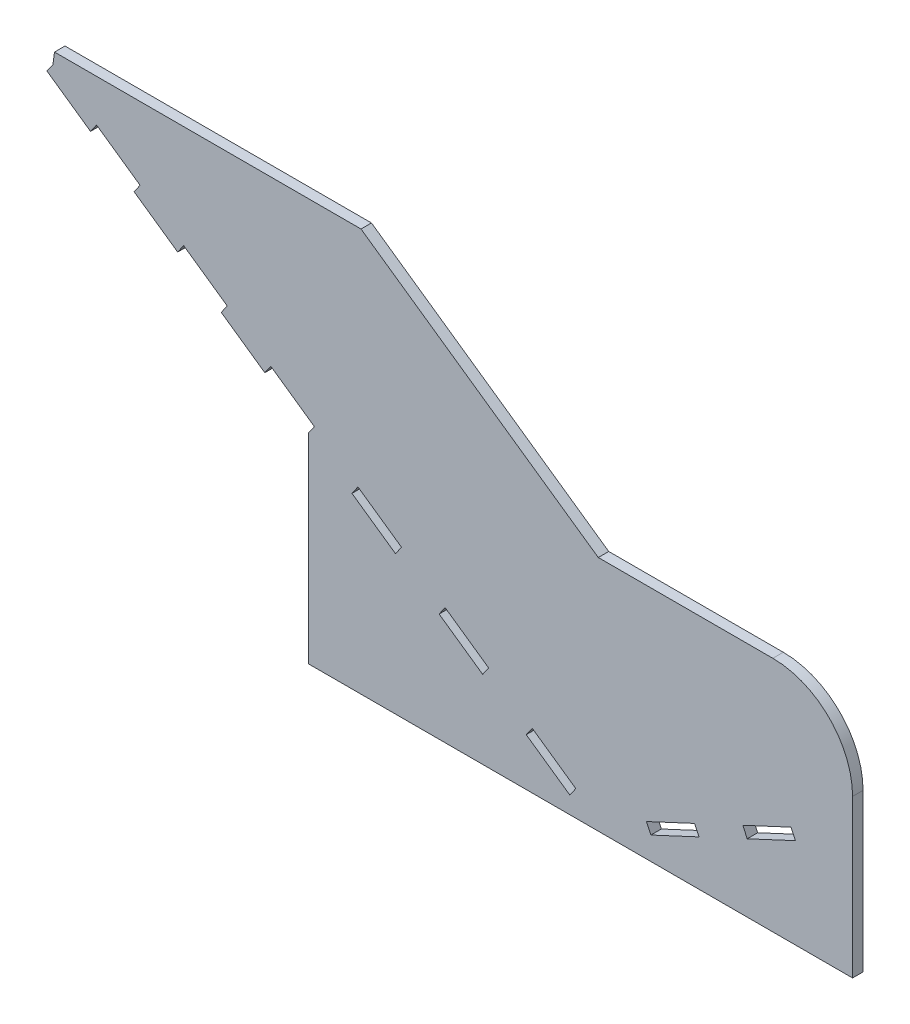
from build123d import *

# Parameters (mm, degrees)
BOSS_EXTRUDE1_DEPTH = 10


with BuildPart() as part:
    # Sketch1 → Boss-Extrude1 (new body)
    with BuildSketch(Plane.XY):
        with BuildLine():
            Line((26.73180705, 202.268045215), (-266.122767511, 202.268045215))
            Line((-266.122767511, 202.268045215), (-267.623671515, 191.109569167))
            Line((-267.623671515, 191.109569167), (-273.353298876, 182.913754973))
            Line((-273.353298876, 182.913754973), (-231.718562767, 153.807247983))
            Line((-231.718562767, 153.807247983), (-225.988935407, 162.003062177))
            Line((-225.988935407, 162.003062177), (-184.354199298, 132.896555187))
            Line((-184.354199298, 132.896555187), (-190.083826658, 124.700740993))
            Line((-190.083826658, 124.700740993), (-148.449090549, 95.594234003))
            Line((-148.449090549, 95.594234003), (-142.719463189, 103.790048198))
            Line((-142.719463189, 103.790048198), (-101.084727081, 74.683541208))
            Line((-101.084727081, 74.683541208), (-106.814354441, 66.487727013))
            Line((-106.814354441, 66.487727013), (-65.179618332, 37.381220023))
            Line((-65.179618332, 37.381220023), (-59.449990972, 45.577034218))
            Line((-59.449990972, 45.577034218), (-17.815254863, 16.470527228))
            Line((-17.815254863, 16.470527228), (-23.544882223, 8.274713033))
            Line((-23.544882223, 8.274713033), (-23.544882223, -182.686538243))
            Line((-23.544882223, -182.686538243), (496.44897172, -182.686538243))
            Line((496.44897172, -182.686538243), (496.44897172, -32.421529871))
            ThreePointArc((496.44897172, -32.421529871), (474.130508447, 21.460006856), (420.24897172, 43.778470129))
            Line((420.24897172, 43.778470129), (253.439588816, 43.778470129))
            Line((253.439588816, 43.778470129), (26.73180705, 202.268045215))
        make_face()
        Polygon((23.819481246, -12.635979762), (65.454217354, -41.742486752), (59.724589994, -49.938300947), (18.089853885, -20.831793957), align=None, mode=Mode.SUBTRACT)
        Polygon((107.088953463, -70.848993742), (148.723689572, -99.955500732), (142.994062212, -108.151314927), (101.359326103, -79.044807937), align=None, mode=Mode.SUBTRACT)
        Polygon((190.358425681, -129.062007722), (231.993161789, -158.168514712), (226.263534429, -166.364328907), (184.62879832, -137.257821917), align=None, mode=Mode.SUBTRACT)
        Polygon((299.480024398, -151.692530547), (345.520459979, -130.22352285), (349.746642597, -139.28660072), (303.706207015, -160.755608417), align=None, mode=Mode.SUBTRACT)
        Polygon((391.560895561, -108.754515154), (437.601331142, -87.285507457), (441.82751376, -96.348585328), (395.787078178, -117.817593024), align=None, mode=Mode.SUBTRACT)
    extrude(amount=BOSS_EXTRUDE1_DEPTH)


solid = part.part
